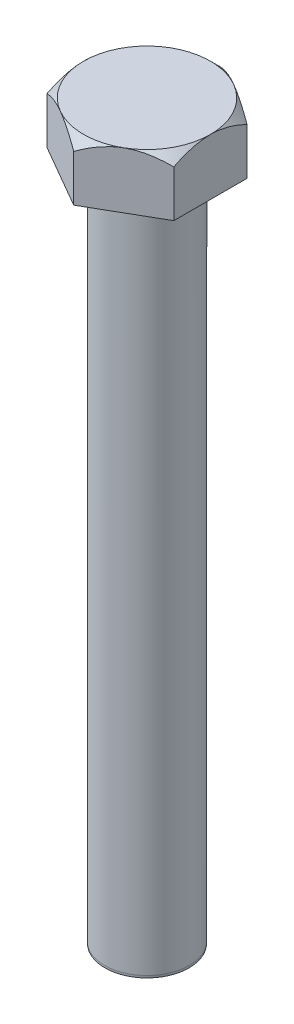
from build123d import *

# Parameters (mm, degrees)
BOSS_EXTRUDE1_DEPTH = 6.35
SKETCH2_R           = 4.7625
BOSS_EXTRUDE2_DEPTH = 76.2
SKETCH3_OUTSIDE_W   = 74.018
SKETCH3_OUTSIDE_H   = 76.23
SKETCH3_OUTSIDE_R   = 7.1501
CUT_EXTRUDE1_DEPTH  = 20.32
CUT_EXTRUDE1_TAPER  = 45
CHAMFER1_SIZE       = 0.254
CHAMFER1_SIZE2      = 0.022222121


with BuildPart() as part:
    # Sketch1 → Boss-Extrude1 (new body)
    with BuildSketch(Plane(origin=(0, 0, 0), x_dir=(1, 0, 0), z_dir=(0, 1, 0))):
        Polygon((0, 8.256224319), (-7.1501, 4.12811216), (-7.1501, -4.12811216), (0, -8.256224319), (7.1501, -4.12811216), (7.1501, 4.12811216), align=None)
    extrude(amount=BOSS_EXTRUDE1_DEPTH)

    # Sketch2 → Boss-Extrude2 (add)
    with BuildSketch(Plane.XZ):
        Circle(SKETCH2_R)
    extrude(amount=BOSS_EXTRUDE2_DEPTH)

    # Sketch3 outside → Cut-Extrude1 (cut)
    with BuildSketch(Plane(origin=(0, 6.35, 0), x_dir=(1, 0, 0), z_dir=(0, 1, 0))):
        Rectangle(SKETCH3_OUTSIDE_W, SKETCH3_OUTSIDE_H)
        Circle(SKETCH3_OUTSIDE_R, mode=Mode.SUBTRACT)
    extrude(amount=-CUT_EXTRUDE1_DEPTH, taper=CUT_EXTRUDE1_TAPER, mode=Mode.SUBTRACT)

    # Chamfer1
    chamfer1_edges = [part.edges().sort_by_distance(p)[0] for p in [
        (-4.7625, -76.2, 0),
    ]]
    chamfer1_side = [part.faces().sort_by_distance(p)[0] for p in [
        (-4.7625, -38.1, 0),
    ]]
    chamfer(chamfer1_edges, length=CHAMFER1_SIZE, length2=CHAMFER1_SIZE2, reference=chamfer1_side[0])


solid = part.part
